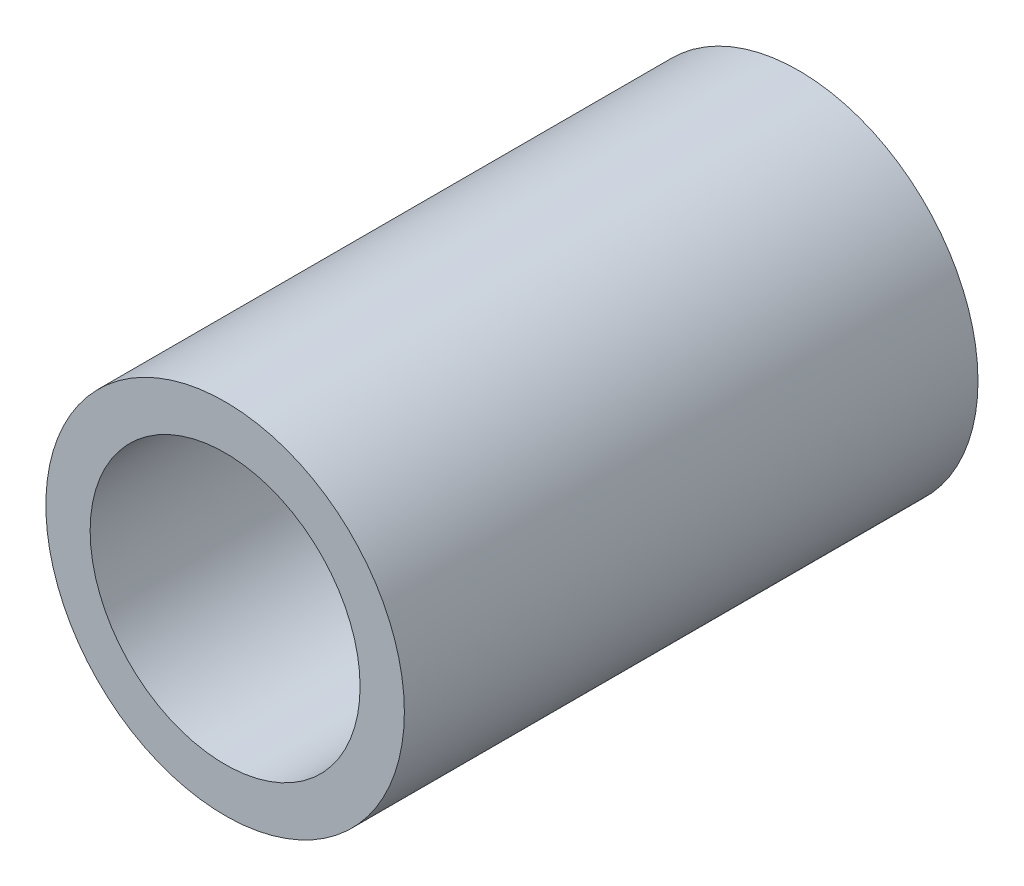
from build123d import *

# Parameters (mm, degrees)
ESQUISSE2_R      = 21.25
ESQUISSE2_R_2    = 16
EXTRUSION1_DEPTH = 34


with BuildPart() as part:
    # Esquisse2 → Extrusion1 (new body, symmetric)
    with BuildSketch(Plane.XY):
        Circle(ESQUISSE2_R)
        Circle(ESQUISSE2_R_2, mode=Mode.SUBTRACT)
    extrude(amount=EXTRUSION1_DEPTH, both=True)


solid = part.part
